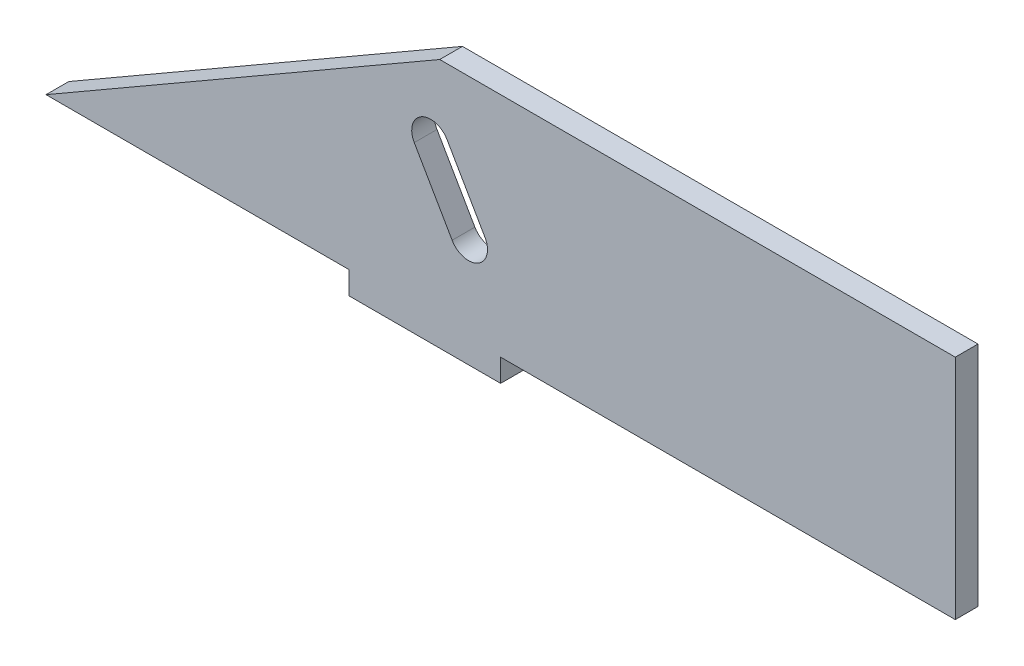
from build123d import *

# Parameters (mm, degrees)
BOSS_EXTRUDE1_DEPTH     = 3
CUT_EXTRUDE3_DEPTH      = 1
CUT_EXTRUDE3_DEPTH_BACK = 3
CUT_EXTRUDE4_DEPTH      = 4
SKETCH6_W               = 3
SKETCH6_H               = 30
BOSS_EXTRUDE2_DEPTH     = 20


with BuildPart() as part:
    # Sketch1 → Boss-Extrude1 (new body)
    with BuildSketch(Plane.XY):
        Polygon((-10, -15), (-10, -18), (10, -18), (10, -15), (50, -15), (50, 15), (-50, 15), (-50, -15), align=None)
    extrude(amount=BOSS_EXTRUDE1_DEPTH)

    # Sketch4 → Cut-Extrude3 (cut, two sides)
    with BuildSketch(Plane.XY.offset(3)) as cut_extrude3_sk:
        Polygon((-50, -14.220304878), (-50, -15), (1.961524227, 15), (-50, 15), align=None)
    extrude(amount=CUT_EXTRUDE3_DEPTH, mode=Mode.SUBTRACT)
    extrude(cut_extrude3_sk.sketch, amount=-CUT_EXTRUDE3_DEPTH_BACK, mode=Mode.SUBTRACT)

    # Sketch5 → Cut-Extrude4 (cut)
    with BuildSketch(Plane.XY.offset(3)):
        with BuildLine():
            Line((7.930435314, -2.338457268), (2.930435314, 6.32179677))
            ThreePointArc((2.930435314, 6.32179677), (-0.484628196, 7.236860279), (-1.399691705, 3.82179677))
            Line((-1.399691705, 3.82179677), (3.600308295, -4.838457268))
            ThreePointArc((3.600308295, -4.838457268), (7.015371804, -5.753520778), (7.930435314, -2.338457268))
        make_face()
    extrude(amount=-CUT_EXTRUDE4_DEPTH, mode=Mode.SUBTRACT)

    # Sketch6 → Boss-Extrude2 (add)
    with BuildSketch(Plane(origin=(50, 0, 0), x_dir=(0, 0, -1), z_dir=(1, 0, 0))):
        with Locations((-1.5, 0)):
            Rectangle(SKETCH6_W, SKETCH6_H)
    extrude(amount=BOSS_EXTRUDE2_DEPTH)


solid = part.part
